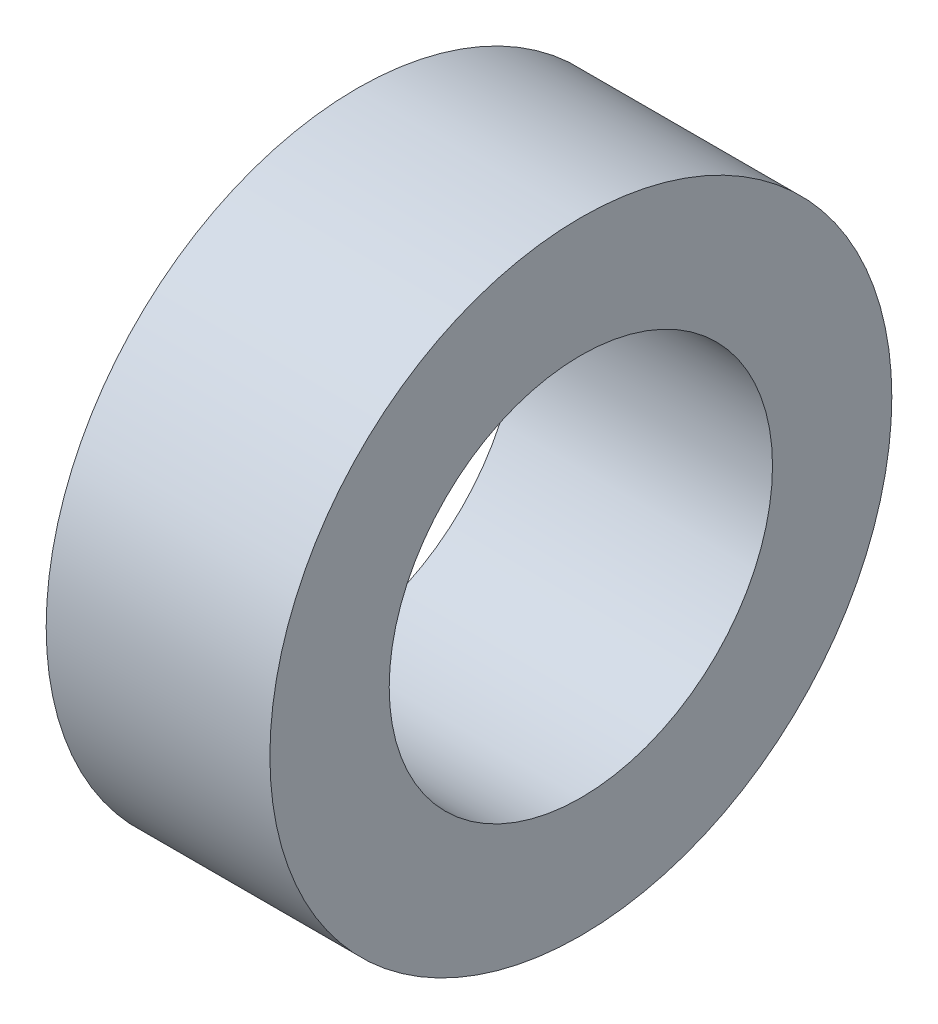
from build123d import *

# Parameters (mm, degrees)
SKETCH1_R           = 11.901099896
SKETCH1_R_2         = 10.2
BOSS_EXTRUDE1_DEPTH = 13.550000078
SKETCH2_R           = 16.55
SKETCH2_R_2         = 10.2
BOSS_EXTRUDE2_DEPTH = 11.90625


with BuildPart() as part:
    # Sketch1 → Boss-Extrude1 (new body)
    with BuildSketch(Plane(origin=(0, 0, 0), x_dir=(0, 0, -1), z_dir=(1, 0, 0))):
        Circle(SKETCH1_R)
        Circle(SKETCH1_R_2, mode=Mode.SUBTRACT)
    extrude(amount=BOSS_EXTRUDE1_DEPTH)

    # Sketch2 → Boss-Extrude2 (add)
    with BuildSketch(Plane(origin=(13.550000078, 0, 0), x_dir=(0, 0, -1), z_dir=(1, 0, 0))):
        Circle(SKETCH2_R)
        Circle(SKETCH2_R_2, mode=Mode.SUBTRACT)
    extrude(amount=-BOSS_EXTRUDE2_DEPTH)


solid = part.part
